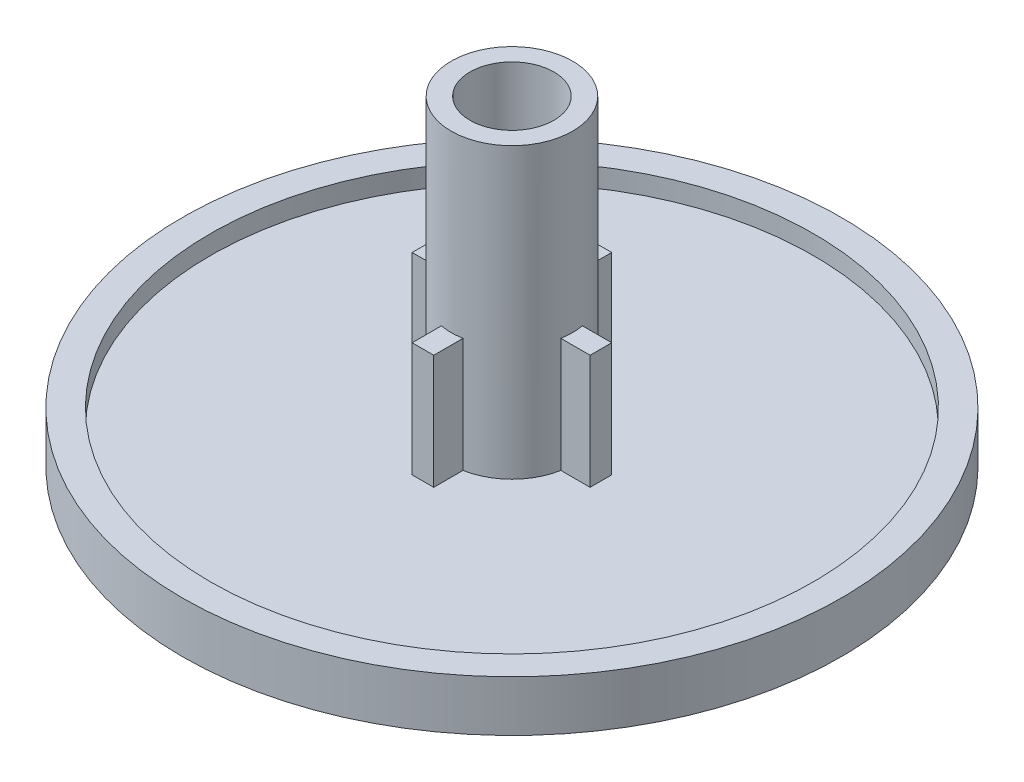
from build123d import *

# Parameters (mm, degrees)
SKETCH1_R           = 13.1699
BOSS_EXTRUDE1_DEPTH = 1.27
SKETCH2_R           = 13.1699
SKETCH2_R_2         = 12.0523
BOSS_EXTRUDE2_DEPTH = 0.762
SKETCH3_R           = 2.4257
BOSS_EXTRUDE3_DEPTH = 11.5443
SKETCH6_W           = 7.112
SKETCH6_H           = 5.842
BOSS_EXTRUDE4_DEPTH = 0.4318
SKETCH7_W           = 7.112
SKETCH7_H           = 5.842
BOSS_EXTRUDE5_DEPTH = 0.4318
SKETCH4_R           = 1.6764
CUT_EXTRUDE1_DEPTH  = 11.5443


with BuildPart() as part:
    # Sketch1 → Boss-Extrude1 (new body)
    with BuildSketch(Plane(origin=(0, 0, 0), x_dir=(1, 0, 0), z_dir=(0, 1, 0))):
        Circle(SKETCH1_R)
    extrude(amount=BOSS_EXTRUDE1_DEPTH)

    # Sketch2 → Boss-Extrude2 (add)
    with BuildSketch(Plane(origin=(0, 1.27, 0), x_dir=(1, 0, 0), z_dir=(0, 1, 0))):
        Circle(SKETCH2_R)
        Circle(SKETCH2_R_2, mode=Mode.SUBTRACT)
    extrude(amount=BOSS_EXTRUDE2_DEPTH)

    # Sketch3 → Boss-Extrude3 (add)
    with BuildSketch(Plane(origin=(0, 1.27, 0), x_dir=(1, 0, 0), z_dir=(0, 1, 0))):
        Circle(SKETCH3_R)
    extrude(amount=BOSS_EXTRUDE3_DEPTH)

    # Sketch6 → Boss-Extrude4 (add, symmetric)
    with BuildSketch(Plane.XY):
        with Locations((0, 2.921)):
            Rectangle(SKETCH6_W, SKETCH6_H)
    extrude(amount=BOSS_EXTRUDE4_DEPTH, both=True)

    # Sketch7 → Boss-Extrude5 (add, symmetric)
    with BuildSketch(Plane(origin=(0, 0, 0), x_dir=(0, 0, -1), z_dir=(1, 0, 0))):
        with Locations((0, 2.921)):
            Rectangle(SKETCH7_W, SKETCH7_H)
    extrude(amount=BOSS_EXTRUDE5_DEPTH, both=True)

    # Sketch4 → Cut-Extrude1 (cut)
    with BuildSketch(Plane(origin=(0, 12.8143, 0), x_dir=(1, 0, 0), z_dir=(0, 1, 0))):
        Circle(SKETCH4_R)
    extrude(amount=-CUT_EXTRUDE1_DEPTH, mode=Mode.SUBTRACT)


solid = part.part
